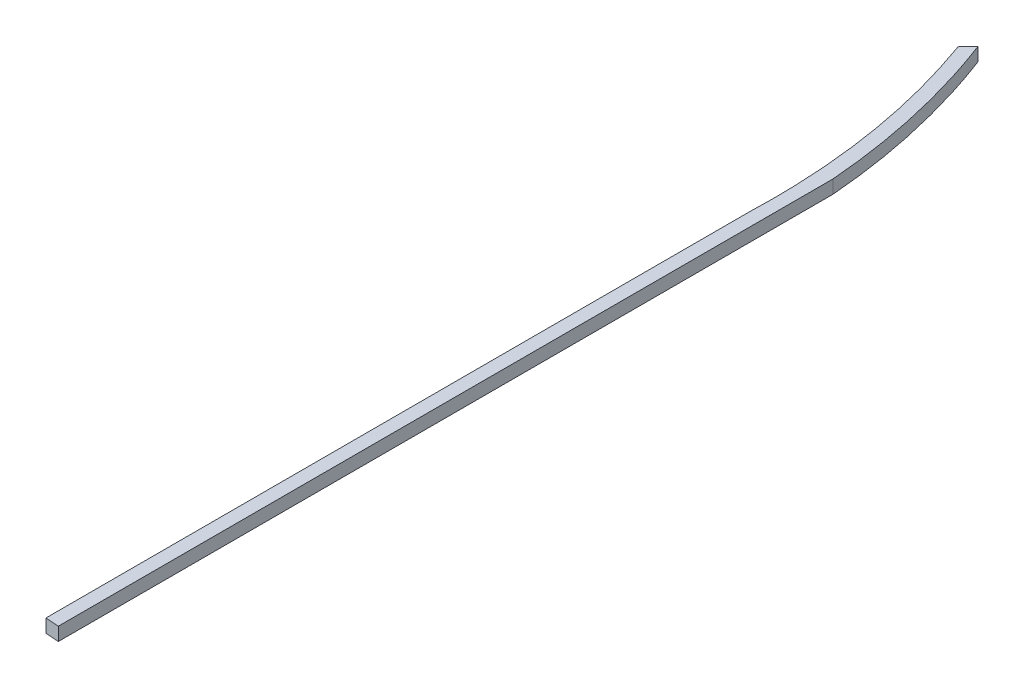
from build123d import *

# Parameters (mm, degrees)
BOSS_EXTRUDE1_DEPTH = 5.7


with BuildPart() as part:
    # Sketch1 → Boss-Extrude1 (new body)
    with BuildSketch(Plane(origin=(0, 0, 0), x_dir=(1, 0, 0), z_dir=(0, 1, 0))):
        with BuildLine():
            Line((0, 0), (0, 301.474))
            add(Edge.make_bspline(
                [(0, 301.474), (1.947152909, 355.934632045), (-16.543745931, 407.327520261)],
                knots=[0, 0, 0, 1, 1, 1], degree=2))
            Line((-16.543745931, 407.327520261), (-12.38816914, 411.710423204))
            add(Edge.make_bspline(
                [(5.7, 331.474), (2.429624829, 372.720008317), (-12.38816914, 411.710423204)],
                knots=[0, 0, 0, 1, 1, 1], degree=2))
            Line((5.7, 331.474), (5.7, 0))
            Line((5.7, 0), (5.7, -0.427567417))
            Line((5.7, -0.427567417), (0, 0))
        make_face()
    extrude(amount=BOSS_EXTRUDE1_DEPTH)


solid = part.part
